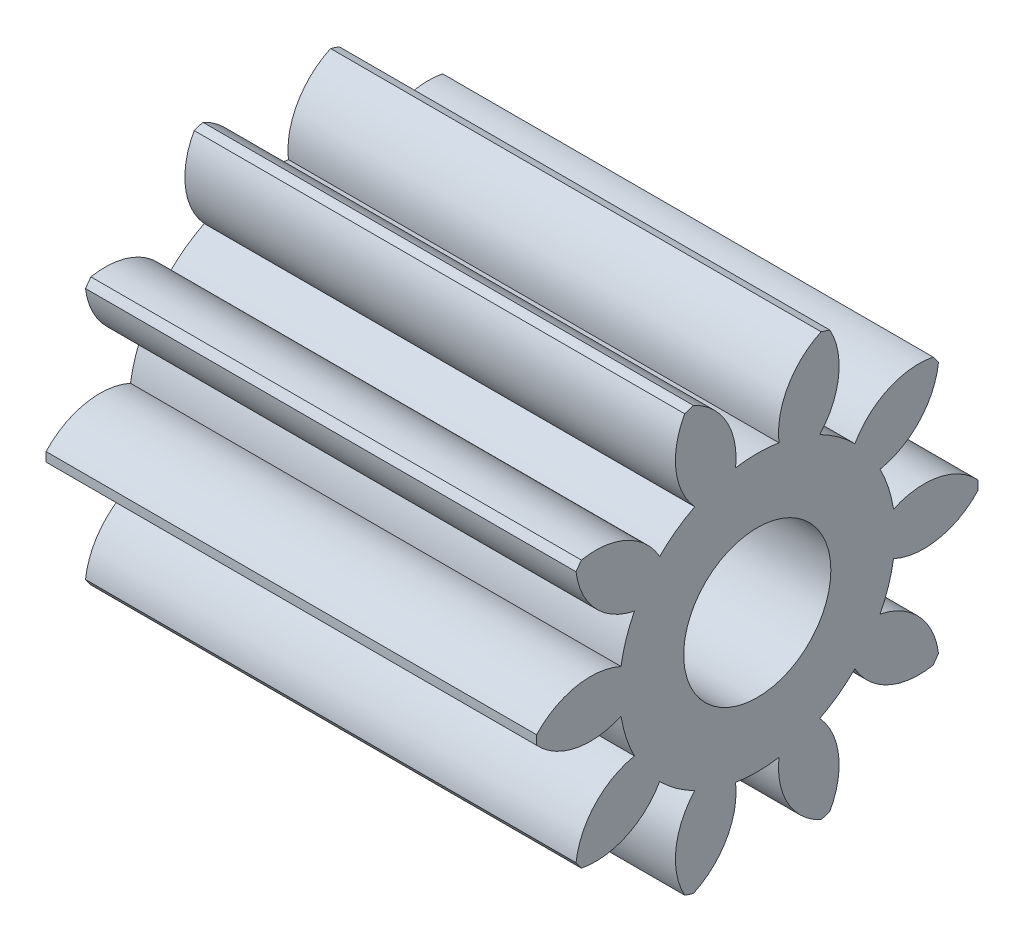
from build123d import *

# Parameters (mm, degrees)
BASPROSKE_W           = 20
BASPROSKE_H           = 9
TOOTHCUT_DEPTH        = 24.706539182
TEETHCUTS_COUNT       = 10
TEETHCUTS_ANGLE       = 324
BORSKE_R              = 2.5
BORE_DEPTH            = 50.0000508
IZIM1_R               = 3
KES_EKSTR_ZYON1_DEPTH = 23


with BuildPart() as part:
    # BasProSke → Base-Revolve (revolve)
    with BuildSketch(Plane(origin=(0, 0, 0), x_dir=(1, 0, 0), z_dir=(0, 1, 0)), mode=Mode.PRIVATE) as base_revolve_sk:
        with Locations((10, 4.5)):
            Rectangle(BASPROSKE_W, BASPROSKE_H)
    revolve(base_revolve_sk.sketch.rotate(Axis((-10, 0, 0), (1, 0, 0)), 180), axis=Axis((-10, 0, 0), (1, 0, 0)))

    # TooCutSke → ToothCut (cut, through all)
    with BuildSketch(Plane(origin=(0, 0, 0), x_dir=(0, 0, -1), z_dir=(1, 0, 0))):
        with BuildLine():
            ThreePointArc((0.883878355, 5.554109745), (0, 5.624), (-0.883878355, 5.554109745))
            ThreePointArc((-0.883878355, 5.554109745), (-1.258245767, 7.379188248), (-2.637816971, 8.631324741))
            ThreePointArc((-2.637816971, 8.631324741), (0, 9.0254), (2.637816971, 8.631324741))
            ThreePointArc((2.637816971, 8.631324741), (1.258245767, 7.379188248), (0.883878355, 5.554109745))
        make_face()
    toothcut = extrude(amount=TOOTHCUT_DEPTH, mode=Mode.SUBTRACT)

    # TeethCuts: ToothCut ×10 about axis
    teethcuts_axis = Axis((-10, 0, 0), (1, 0, 0))
    for i in range(1, TEETHCUTS_COUNT):
        add(toothcut.rotate(teethcuts_axis, i * TEETHCUTS_ANGLE / (TEETHCUTS_COUNT - 1)), mode=Mode.SUBTRACT)

    # BorSke → Bore (cut, symmetric)
    with BuildSketch(Plane(origin=(0, 0, 0), x_dir=(0, 0, -1), z_dir=(1, 0, 0))):
        with Locations(Location((0, 0, 0), (0, 0, 180))):
            Circle(BORSKE_R)
    extrude(amount=BORE_DEPTH, both=True, mode=Mode.SUBTRACT)

    # Çizim1 → Kes-Ekstrüzyon1 (cut)
    with BuildSketch(Plane(origin=(20, 0, 0), x_dir=(0, 0, -1), z_dir=(1, 0, 0))):
        Circle(IZIM1_R)
    extrude(amount=-KES_EKSTR_ZYON1_DEPTH, mode=Mode.SUBTRACT)


solid = part.part
